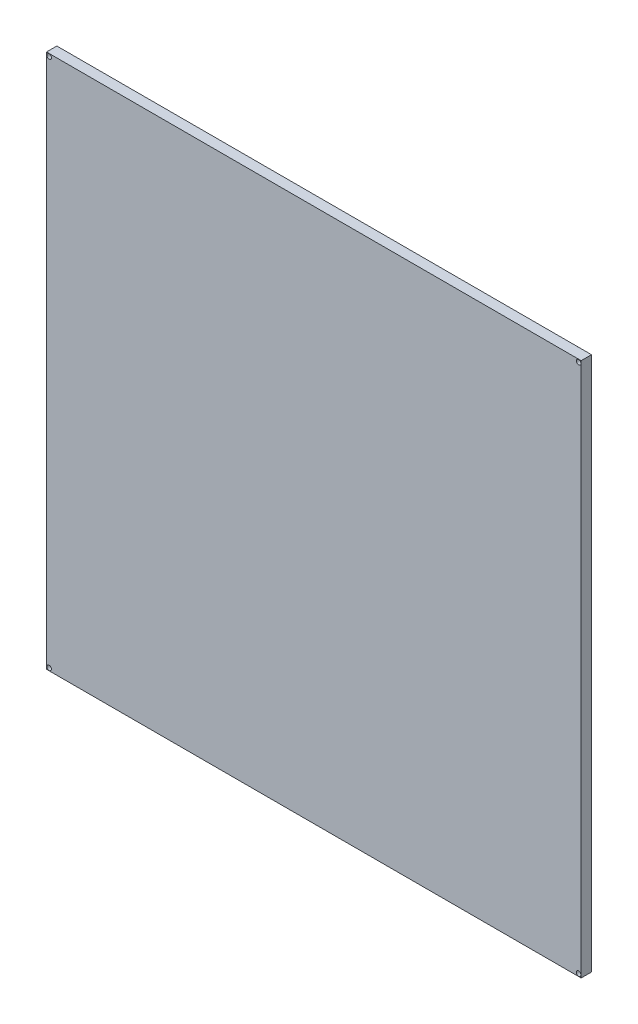
from build123d import *

# Parameters (mm, degrees)
SKETCH1_W           = 51.8
SKETCH1_H           = 51.8
BOSS_EXTRUDE1_DEPTH = 1
SKETCH2_R           = 0.225
CUT_EXTRUDE1_DEPTH  = 2


with BuildPart() as part:
    # Sketch1 → Boss-Extrude1 (new body)
    with BuildSketch(Plane.XY):
        with Locations((12.751804073, -1.850317184)):
            Rectangle(SKETCH1_W, SKETCH1_H)
    extrude(amount=BOSS_EXTRUDE1_DEPTH)

    # Sketch2 → Cut-Extrude1 (cut, through all)
    with BuildSketch(Plane(origin=(0, 0, 0), x_dir=(-1, 0, 0), z_dir=(0, 0, -1))):
        with Locations((-38.404785349, 23.800967778)):
            Circle(SKETCH2_R)
        with Locations((-38.404785349, -27.501602145)):
            Circle(SKETCH2_R)
        with Locations((12.89435689, -27.501602145)):
            Circle(SKETCH2_R)
        with Locations((12.89435689, 23.800967778)):
            Circle(SKETCH2_R)
    extrude(amount=-CUT_EXTRUDE1_DEPTH, mode=Mode.SUBTRACT)


solid = part.part
